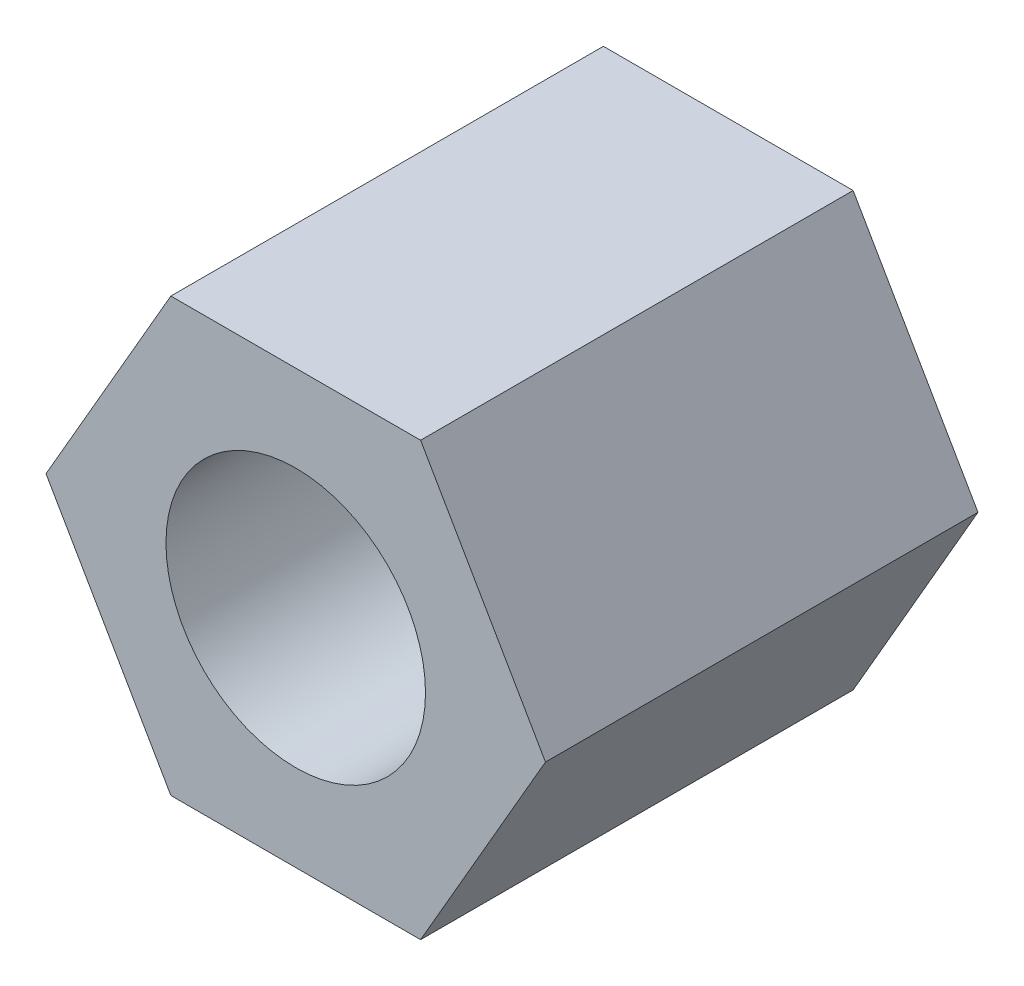
from build123d import *

# Parameters (mm, degrees)
SKETCH_1_R      = 1.5
EXTRUDE_1_DEPTH = 5


with BuildPart() as part:
    # 草图1 → 凸台-拉伸1 (new body)
    with BuildSketch(Plane.XY):
        Polygon((1.443375673, -2.5), (2.886751346, 0), (1.443375673, 2.5), (-1.443375673, 2.5), (-2.886751346, 0), (-1.443375673, -2.5), align=None)
        Circle(SKETCH_1_R, mode=Mode.SUBTRACT)
    extrude(amount=EXTRUDE_1_DEPTH)


solid = part.part
